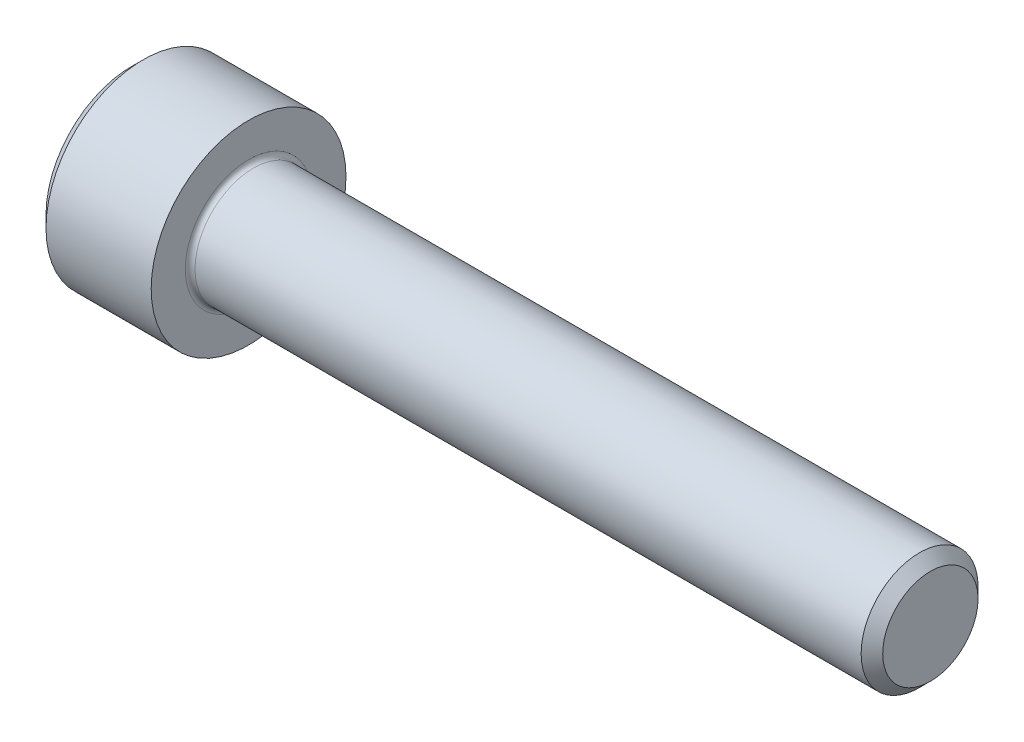
from build123d import *

# Parameters (mm, degrees)
FILLET1_R   = 0.25
HEX_2_DEPTH = 3


with BuildPart() as part:
    # BodySke → Base-Revolve (revolve)
    with BuildSketch(Plane.XY):
        Polygon((0, 0), (0, 4.4), (0.6, 5), (6, 5), (6, 3), (40.4455, 3), (41, 2.4455), (41, 0), align=None)
    revolve(axis=Axis((-31.75, 0, 0), (1, 0, 0)))

    # Fillet1
    fillet1_edges = [part.edges().sort_by_distance(p)[0] for p in [
        (6, -3, 0),
    ]]
    fillet(fillet1_edges, radius=FILLET1_R)

    # Sketch2 → Hex-PreBroach (revolve, cut)
    with BuildSketch(Plane.XY):
        Polygon((0, 2.542), (3, 2.542), (4.467624384, 0), (0, 0), align=None)
    revolve(axis=Axis((0, 0, 0), (1, 0, 0)), mode=Mode.SUBTRACT)

    # Sketch3 → Hex 2 (cut)
    with BuildSketch(Plane(origin=(0, 0, 0), x_dir=(0, 0.5, 0.866025404), z_dir=(-1, 0, 0))):
        Polygon((1.467624384, 2.542), (-1.467624384, 2.542), (-2.935248769, 0), (-1.467624384, -2.542), (1.467624384, -2.542), (2.935248769, 0), align=None)
    extrude(amount=-HEX_2_DEPTH, mode=Mode.SUBTRACT)


solid = part.part
